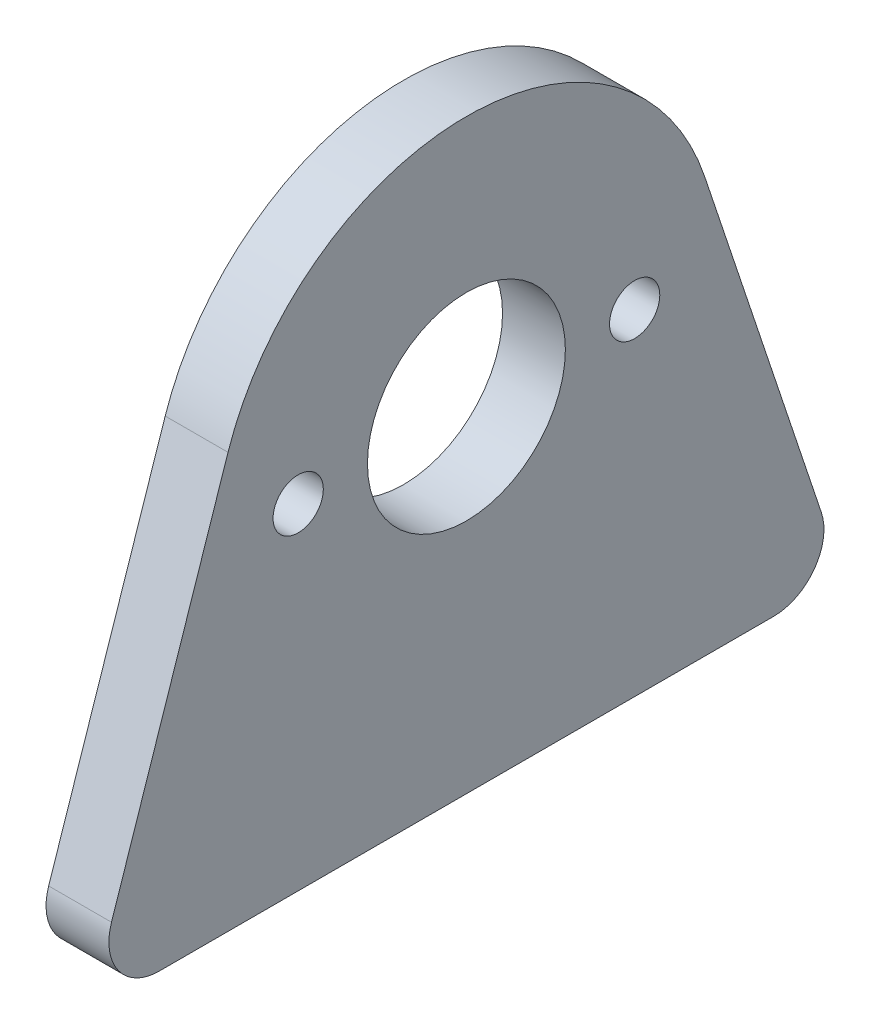
from build123d import *

# Parameters (mm, degrees)
SKETCH1_R           = 12.7
SKETCH1_R_2         = 5
SKETCH1_R_3         = 1.27
BOSS_EXTRUDE1_DEPTH = 3.175
FILLET1_R           = 2.54
FILLET2_R           = 2.54


with BuildPart() as part:
    # Sketch1 → Boss-Extrude1 (new body)
    with BuildSketch(Plane(origin=(0, 0, 0), x_dir=(0, 0, -1), z_dir=(1, 0, 0))):
        with BuildLine():
            Line((-19.05, -16.938), (0, -16.938))
            Line((0, -16.938), (19.05, -16.938))
            Line((19.05, -16.938), (12.045339341, 4.024897535))
            ThreePointArc((12.045339341, 4.024897535), (12.535266444, 2.03889558), (12.7, 0))
            ThreePointArc((12.7, 0), (-2.03889558, -12.535266444), (-12.045339341, 4.024897535))
            Line((-12.045339341, 4.024897535), (-19.05, -16.938))
        make_face()
        Circle(SKETCH1_R)
        Circle(SKETCH1_R_2, mode=Mode.SUBTRACT)
        with Locations((-8.5, 0)):
            Circle(SKETCH1_R_3, mode=Mode.SUBTRACT)
        with Locations((8.5, 0)):
            Circle(SKETCH1_R_3, mode=Mode.SUBTRACT)
    extrude(amount=-BOSS_EXTRUDE1_DEPTH)

    # Fillet1
    fillet1_edges = [part.edges().sort_by_distance(p)[0] for p in [
        (-1.5875, -16.938, -19.05),
    ]]
    fillet(fillet1_edges, radius=FILLET1_R)

    # Fillet2
    fillet2_edges = [part.edges().sort_by_distance(p)[0] for p in [
        (-1.5875, -16.938, 19.05),
    ]]
    fillet(fillet2_edges, radius=FILLET2_R)


solid = part.part
